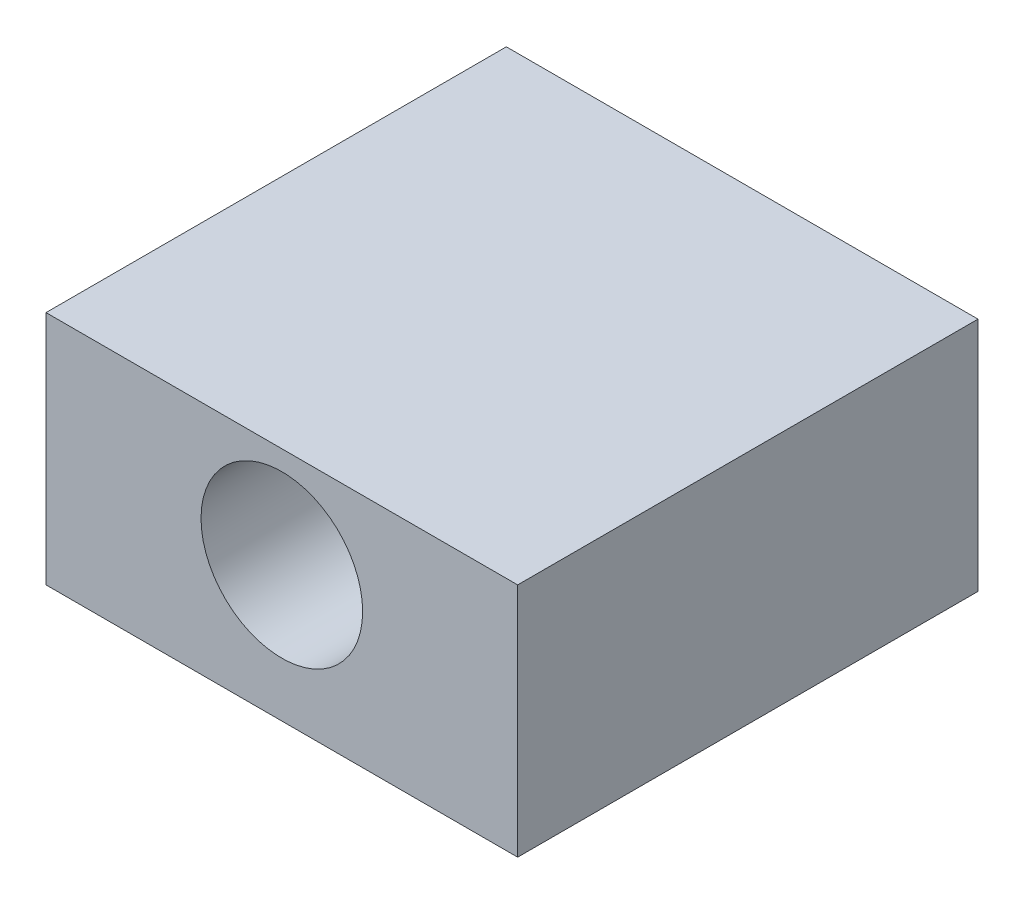
from build123d import *

# Parameters (mm, degrees)
SKETCH1_W                   = 19.05
SKETCH1_H                   = 9.525
EXTRUDE1_DEPTH              = 18.5928
F_1_4_CLEARANCE_HOLE1_D     = 6.5278
F_1_4_CLEARANCE_HOLE1_DEPTH = 15.24
F_1_4_CLEARANCE_HOLE1_TIP   = 1.961148974


with BuildPart() as part:
    # Sketch1 → Extrude1 (new body)
    with BuildSketch(Plane.XY):
        Rectangle(SKETCH1_W, SKETCH1_H)
    extrude(amount=EXTRUDE1_DEPTH)

    # 1/4 Clearance Hole1
    with Locations(Plane(origin=(0, 0.6985, 18.5928), x_dir=(1, 0, 0), z_dir=(0, 0, 1))):
        with Locations((0, 0)):
            Hole(F_1_4_CLEARANCE_HOLE1_D / 2, depth=F_1_4_CLEARANCE_HOLE1_DEPTH)
            with Locations((0, 0, -(F_1_4_CLEARANCE_HOLE1_DEPTH + F_1_4_CLEARANCE_HOLE1_TIP / 2))):  # 118° drill point
                Cone(0, F_1_4_CLEARANCE_HOLE1_D / 2, F_1_4_CLEARANCE_HOLE1_TIP, mode=Mode.SUBTRACT)


solid = part.part
